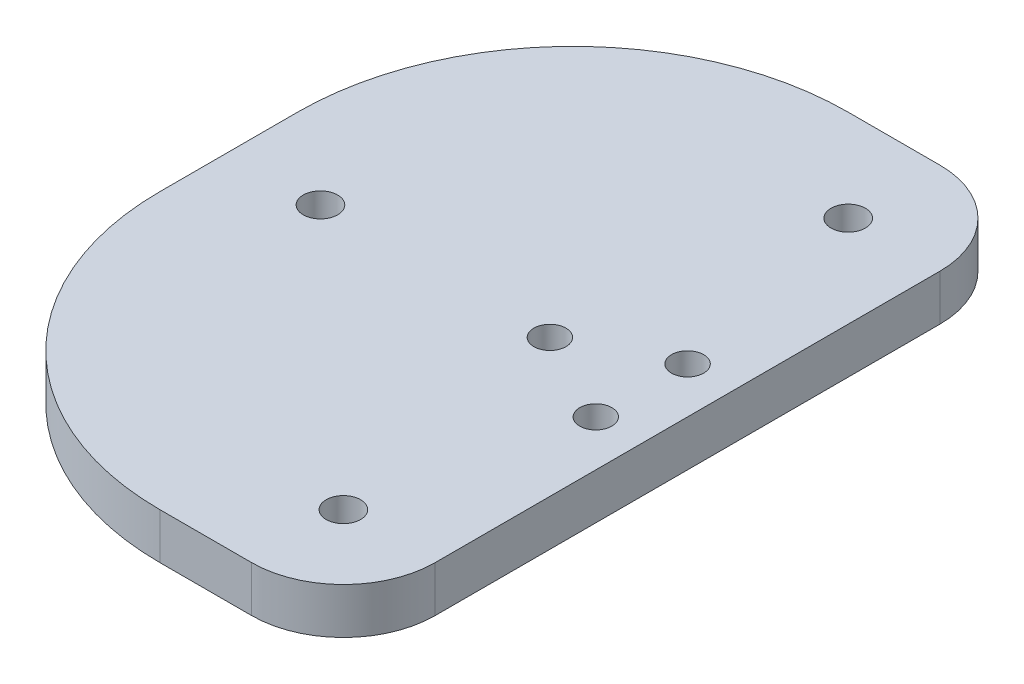
from build123d import *

# Parameters (mm, degrees)
SKETCH1_W           = 50
SKETCH1_H           = 75
SKETCH1_R           = 1.875
SKETCH1_R_2         = 1.75
BOSS_EXTRUDE1_DEPTH = 5
SKETCH2_R           = 3
CUT_EXTRUDE1_DEPTH  = 2.5
FILLET1_R           = 30
FILLET2_R           = 10


with BuildPart() as part:
    # Sketch1 → Boss-Extrude1 (new body)
    with BuildSketch(Plane(origin=(0, 0, 0), x_dir=(1, 0, 0), z_dir=(0, 1, 0))):
        with Locations((25, 37.5)):
            Rectangle(SKETCH1_W, SKETCH1_H)
        with Locations((40, 65)):
            Circle(SKETCH1_R, mode=Mode.SUBTRACT)
        with Locations((40, 10)):
            Circle(SKETCH1_R, mode=Mode.SUBTRACT)
        with Locations((10, 37.5)):
            Circle(SKETCH1_R, mode=Mode.SUBTRACT)
        with Locations((45, 42.5)):
            Circle(SKETCH1_R_2, mode=Mode.SUBTRACT)
        with Locations((45, 32.5)):
            Circle(SKETCH1_R_2, mode=Mode.SUBTRACT)
        with Locations((35, 37.5)):
            Circle(SKETCH1_R_2, mode=Mode.SUBTRACT)
    extrude(amount=BOSS_EXTRUDE1_DEPTH)

    # Sketch2 → Cut-Extrude1 (cut)
    with BuildSketch(Plane.XZ):
        with Locations((45, -32.5)):
            Circle(SKETCH2_R)
        with Locations((45, -42.5)):
            Circle(SKETCH2_R)
        with Locations((35, -37.5)):
            Circle(SKETCH2_R)
    extrude(amount=-CUT_EXTRUDE1_DEPTH, mode=Mode.SUBTRACT)

    # Fillet1
    fillet1_edges = [part.edges().sort_by_distance(p)[0] for p in [
        (0, 2.5, -75),
        (0, 2.5, 0),
    ]]
    fillet(fillet1_edges, radius=FILLET1_R)

    # Fillet2
    fillet2_edges = [part.edges().sort_by_distance(p)[0] for p in [
        (50, 2.5, -75),
        (50, 2.5, 0),
    ]]
    fillet(fillet2_edges, radius=FILLET2_R)


solid = part.part
